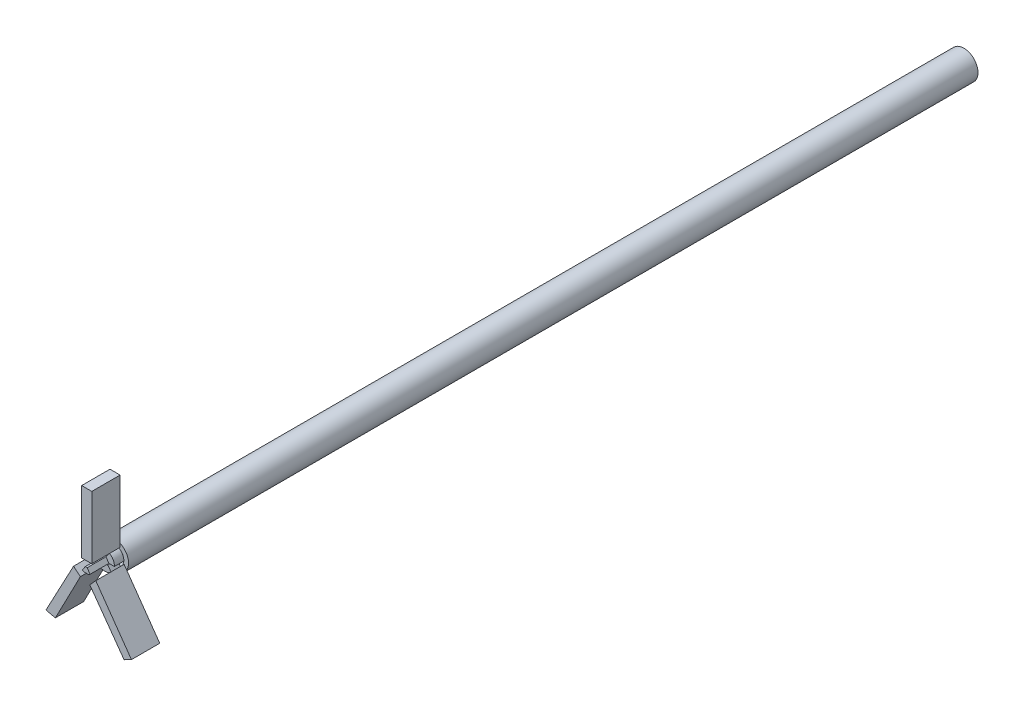
from build123d import *

# Parameters (mm, degrees)
SKETCH1_R           = 15
SKETCH1_R_2         = 10
BOSS_EXTRUDE1_DEPTH = 900
BOSS_EXTRUDE2_DEPTH = 30
BOSS_EXTRUDE4_DEPTH = 10


with BuildPart() as part:
    # Sketch1 → Boss-Extrude1 (new body)
    with BuildSketch(Plane.XY):
        Circle(SKETCH1_R)
        Circle(SKETCH1_R_2, mode=Mode.SUBTRACT)
    extrude(amount=BOSS_EXTRUDE1_DEPTH)

    # Sketch2 → Boss-Extrude2 (add)
    with BuildSketch(Plane.XY.offset(900)):
        Polygon((-0.85478257, 3.876059116), (1.14521743, 3.876059116), (4.19376888, -0.656600178), (2.534207314, -1.772779111), (-2.047481707, -1.597158437), (-3.812517163, -0.656600178), align=None)
        Polygon((-4.663745729, 9.880160695), (-4.663745729, 76.347459395), (6.069206624, 76.347459395), (6.069206624, 9.980020324), align=None)
        Polygon((10.306591378, -3.466467261), (48.075717555, -57.020753709), (40.303795306, -61.029026621), (3.945586725, -10.423127604), align=None)
        Polygon((-5.999013415, -7.943664027), (-32.560420893, -59.083641078), (-42.445609172, -56.749852712), (-13.232089487, -1.928264015), align=None)
    extrude(amount=BOSS_EXTRUDE2_DEPTH)

    # Sketch3 → Boss-Extrude4 (add)
    with BuildSketch(Plane.XY.offset(900)):
        with BuildLine():
            Line((4.19376888, -0.656600178), (9.978420527, -0.656600178))
            ThreePointArc((9.978420527, -0.656600178), (8.766423841, 4.811425261), (4.804554447, 8.770191364))
            Line((4.804554447, 8.770191364), (1.14521743, 3.876059116))
            Line((1.14521743, 3.876059116), (4.19376888, -0.656600178))
        make_face()
        with BuildLine():
            Line((-2.495519996, -2.45978847), (-5.541424945, -8.324218256))
            ThreePointArc((-5.541424945, -8.324218256), (0.624061097, -9.980508391), (6.535201584, -7.569091112))
            Line((6.535201584, -7.569091112), (3.04691128, -2.515542521))
            Line((3.04691128, -2.515542521), (2.534207314, -2.869444387))
            Line((2.534207314, -2.869444387), (-2.047481707, -2.692493454))
            Line((-2.047481707, -2.692493454), (-2.495519996, -2.45978847))
        make_face()
        with BuildLine():
            Line((-0.85478257, 3.876059116), (-3.812517163, -0.656600178))
            Line((-3.812517163, -0.656600178), (-9.978420527, -0.656600178))
            ThreePointArc((-9.978420527, -0.656600178), (-8.766423841, 4.811425261), (-4.804554447, 8.770191364))
            Line((-4.804554447, 8.770191364), (-0.85478257, 3.876059116))
        make_face()
    extrude(amount=BOSS_EXTRUDE4_DEPTH)


solid = part.part
